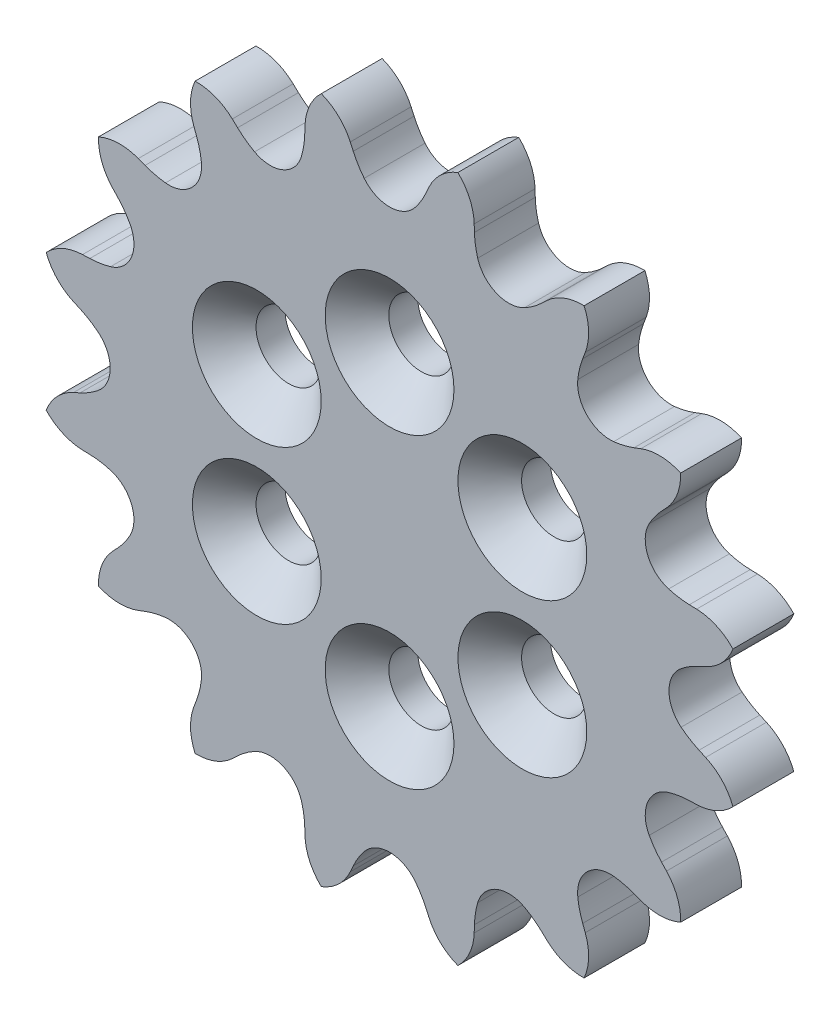
from build123d import *

# Parameters (mm, degrees)
SKETCH3_R                    = 18.654838605
BOSS_EXTRUDE1_DEPTH          = 3.175
CUT_EXTRUDE1_START           = -1
CUT_EXTRUDE1_DEPTH           = 5.175
CIRPATTERN1_COUNT            = 16
CSK_FOR_M3_SFHCS1_AT_2_COUNT = 2
CSK_FOR_M3_SFHCS1_AT_2_PITCH = 8
CSK_FOR_M3_SFHCS1_AT_3_COUNT = 2
CSK_FOR_M3_SFHCS1_AT_3_PITCH = 13.856406461
CSK_FOR_M3_SFHCS1_AT_4_COUNT = 2
CSK_FOR_M3_SFHCS1_AT_4_PITCH = 16
CSK_FOR_M3_SFHCS1_AT_5_COUNT = 2
CSK_FOR_M3_SFHCS1_AT_5_PITCH = 13.856406461
CSK_FOR_M3_SFHCS1_AT_6_COUNT = 2
CSK_FOR_M3_SFHCS1_AT_6_PITCH = 8


with BuildPart() as part:
    # Sketch3 → Boss-Extrude1 (new body)
    with BuildSketch(Plane.XY):
        Circle(SKETCH3_R)
    extrude(amount=BOSS_EXTRUDE1_DEPTH)

    # Sketch2 → Cut-Extrude1 (cut)
    with BuildSketch(Plane.XY.offset(CUT_EXTRUDE1_START)):
        with BuildLine():
            Line((101.443267524, 18.095471295), (4.533974194, 18.095471295))
            ThreePointArc((4.533974194, 18.095471295), (3.056004647, 17.659429879), (2.051408678, 16.490963774))
            Line((2.051408678, 16.490963774), (1.895951627, 16.145861918))
            ThreePointArc((1.895951627, 16.145861918), (1.639424454, 15.660854777), (1.323740827, 15.212098758))
            ThreePointArc((1.323740827, 15.212098758), (0, 14.577158093), (-1.323740827, 15.212098758))
            ThreePointArc((-1.323740827, 15.212098758), (-1.639424454, 15.660854777), (-1.895951627, 16.145861918))
            Line((-1.895951627, 16.145861918), (-2.051408678, 16.490963774))
            ThreePointArc((-2.051408678, 16.490963774), (-3.056004647, 17.659429879), (-4.533974194, 18.095471295))
            Line((-4.533974194, 18.095471295), (-101.443267524, 18.095471295))
            Line((-101.443267524, 18.095471295), (-101.443267524, 211.914057954))
            Line((-101.443267524, 211.914057954), (101.443267524, 211.914057954))
            Line((101.443267524, 211.914057954), (101.443267524, 18.095471295))
        make_face()
    cut_extrude1 = extrude(amount=CUT_EXTRUDE1_DEPTH, mode=Mode.SUBTRACT)

    # CirPattern1: Cut-Extrude1 ×16 about axis
    cirpattern1_axis = Axis((0, 0, -80.9), (0, 0, 1))
    for i in range(1, CIRPATTERN1_COUNT):
        add(cut_extrude1.rotate(cirpattern1_axis, i * 360 / CIRPATTERN1_COUNT), mode=Mode.SUBTRACT)

    # Sketch5 → CSK for M3 SFHCS1 (revolve, cut)
    with BuildSketch(Plane(origin=(0, 8, 3.175), x_dir=(0, -1, 0), z_dir=(1, 0, 0))):
        Polygon((0, 0), (0, 3.175), (1.7, 3.175), (1.7, 1.66), (3.36, 0), align=None)
    csk_for_m3_sfhcs1 = revolve(axis=Axis((0, 8, 9.525), (0, 0, -1)), mode=Mode.SUBTRACT)

    # CSK for M3 SFHCS1 at 2: CSK for M3 SFHCS1 ×2
    with Locations(*[Vector(0.866025404, -0.5, 0) * (i * CSK_FOR_M3_SFHCS1_AT_2_PITCH) for i in range(1, CSK_FOR_M3_SFHCS1_AT_2_COUNT)]):
        add(csk_for_m3_sfhcs1, mode=Mode.SUBTRACT)

    # CSK for M3 SFHCS1 at 3: CSK for M3 SFHCS1 ×2
    with Locations(*[Vector(0.5, -0.866025404, 0) * (i * CSK_FOR_M3_SFHCS1_AT_3_PITCH) for i in range(1, CSK_FOR_M3_SFHCS1_AT_3_COUNT)]):
        add(csk_for_m3_sfhcs1, mode=Mode.SUBTRACT)

    # CSK for M3 SFHCS1 at 4: CSK for M3 SFHCS1 ×2
    with Locations(*[(0, -i * CSK_FOR_M3_SFHCS1_AT_4_PITCH, 0) for i in range(1, CSK_FOR_M3_SFHCS1_AT_4_COUNT)]):
        add(csk_for_m3_sfhcs1, mode=Mode.SUBTRACT)

    # CSK for M3 SFHCS1 at 5: CSK for M3 SFHCS1 ×2
    with Locations(*[Vector(-0.5, -0.866025404, 0) * (i * CSK_FOR_M3_SFHCS1_AT_5_PITCH) for i in range(1, CSK_FOR_M3_SFHCS1_AT_5_COUNT)]):
        add(csk_for_m3_sfhcs1, mode=Mode.SUBTRACT)

    # CSK for M3 SFHCS1 at 6: CSK for M3 SFHCS1 ×2
    with Locations(*[Vector(-0.866025404, -0.5, 0) * (i * CSK_FOR_M3_SFHCS1_AT_6_PITCH) for i in range(1, CSK_FOR_M3_SFHCS1_AT_6_COUNT)]):
        add(csk_for_m3_sfhcs1, mode=Mode.SUBTRACT)


solid = part.part
